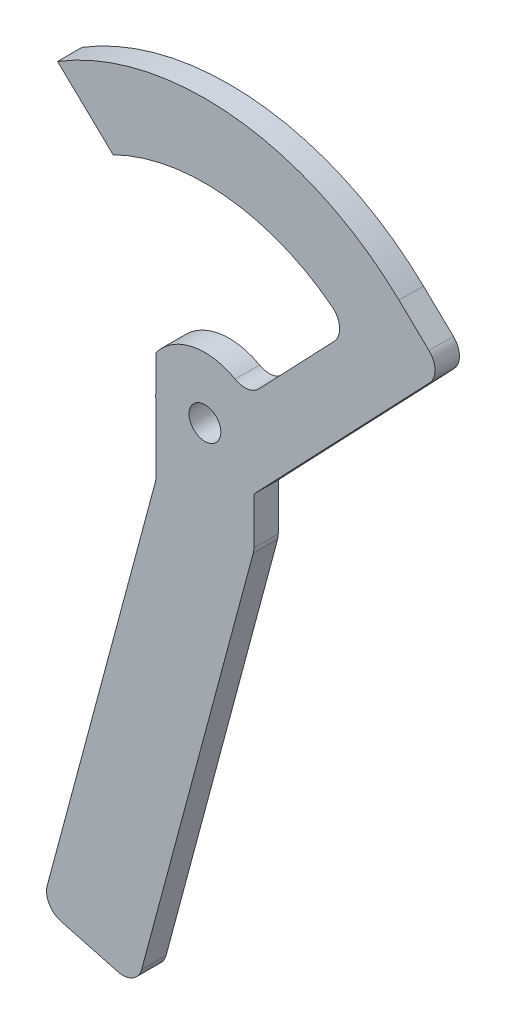
from build123d import *

# Parameters (mm, degrees)
MODEL_R             = 3.25
BOSS_EXTRUDE1_DEPTH = 5


with BuildPart() as part:
    # Model → Boss-Extrude1 (new body)
    with BuildSketch(Plane.XY):
        with BuildLine():
            Line((350.531086943, 258.379089544), (344.410544625, 264.21942133))
            ThreePointArc((344.410544625, 264.21942133), (310.747790065, 279.802358255), (274.574415573, 271.586766634))
            Line((274.574415573, 271.586766634), (285.935808975, 260.74552029))
            ThreePointArc((285.935808975, 260.74552029), (308.96264008, 264.906909994), (330.701924732, 256.249218742))
            ThreePointArc((330.701924732, 256.249218742), (332.244741838, 253.385658556), (331.150021748, 250.322678066))
            Line((331.150021748, 250.322678066), (315.766337555, 234.200907326))
            ThreePointArc((315.766337555, 234.200907326), (313.453795395, 233.004786403), (310.89495725, 233.485310955))
            ThreePointArc((310.89495725, 233.485310955), (302.169602206, 234.857703267), (294.715316918, 230.11967497))
            Line((294.715316918, 230.11967497), (294.715316918, 222.972135785))
            ThreePointArc((294.715316918, 222.972135785), (294.657727687, 222.677637577), (294.643218038, 222.377912396))
            ThreePointArc((294.643218038, 222.377912396), (294.667183717, 221.884389879), (294.715316918, 221.392635851))
            Line((294.715316918, 221.392635851), (294.715316918, 208.14628496))
            ThreePointArc((294.715316918, 208.14628496), (294.681096364, 207.624180191), (294.579020223, 207.11100878))
            Line((294.579020223, 207.11100878), (272.456879039, 124.550053909))
            ThreePointArc((272.456879039, 124.550053909), (272.856480729, 121.514777728), (275.285306164, 119.651074423))
            Line((275.285306164, 119.651074423), (286.876416079, 116.545245882))
            ThreePointArc((286.876416079, 116.545245882), (289.91169226, 116.944847572), (291.775395565, 119.373673007))
            Line((291.775395565, 119.373673007), (314.579020223, 204.477958828))
            ThreePointArc((314.579020223, 204.477958828), (314.681096364, 204.991130239), (314.715316918, 205.513235008))
            Line((314.715316918, 205.513235008), (314.715316918, 215.05078415))
            Line((314.715316918, 215.05078415), (350.663575197, 252.723787))
            ThreePointArc((350.663575197, 252.723787), (351.768582577, 255.578877488), (350.531086943, 258.379089544))
        make_face()
        with Locations((304.715316918, 222.61967497)):
            Circle(MODEL_R, mode=Mode.SUBTRACT)
    extrude(amount=BOSS_EXTRUDE1_DEPTH)


solid = part.part
